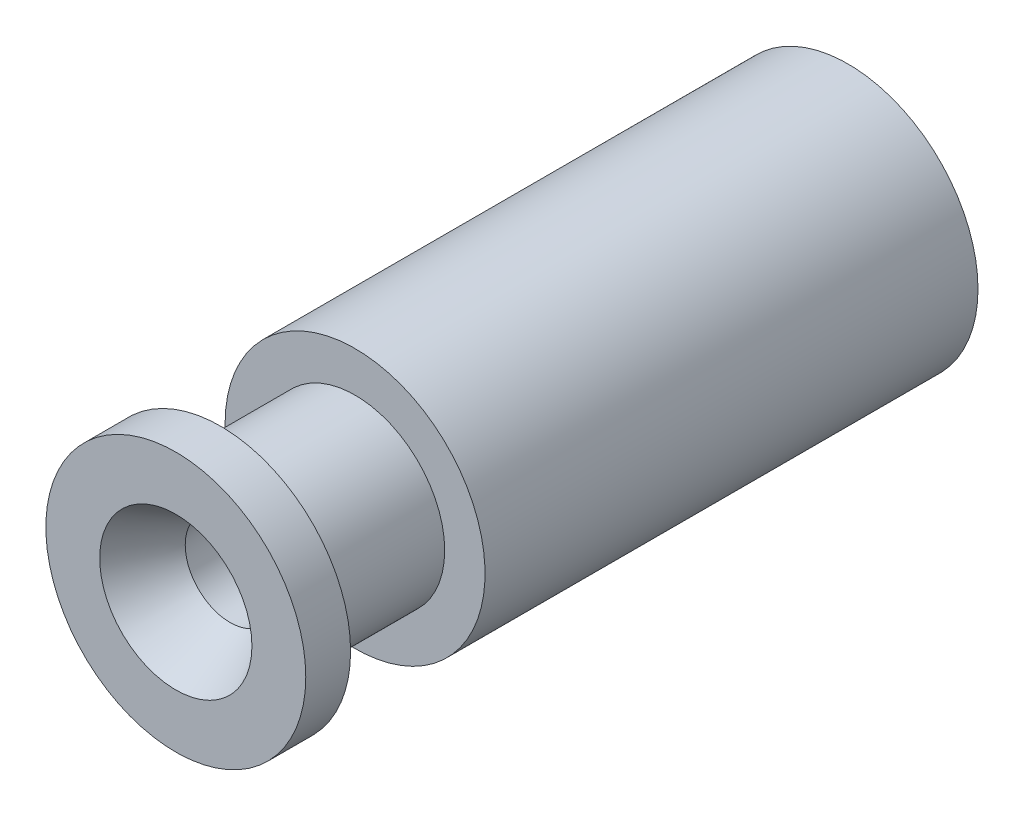
from build123d import *

# Parameters (mm, degrees)
SKETCH1_R                       = 2.9
BOSS_EXTRUDE1_DEPTH             = 15
SKETCH2_R                       = 1
CUT_EXTRUDE1_DEPTH              = 16
TAP_DRILL_FOR_M3X0_5_TAP1_D     = 2.5
TAP_DRILL_FOR_M3X0_5_TAP1_DEPTH = 11
TAP_DRILL_FOR_M3X0_5_TAP1_TIP   = 0.751075774
SKETCH5_W                       = 3
SKETCH5_H                       = 1.793791595
CHAMFER1_SIZE                   = 0.75
CHAMFER1_SIZE2                  = 1.299038106
CHAMFER2_SIZE                   = 1.21
CHAMFER2_SIZE2                  = 0.698593826


with BuildPart() as part:
    # Sketch1 → Boss-Extrude1 (new body)
    with BuildSketch(Plane.XY):
        Circle(SKETCH1_R)
    extrude(amount=BOSS_EXTRUDE1_DEPTH)

    # Sketch2 → Cut-Extrude1 (cut, through all)
    with BuildSketch(Plane(origin=(0, 0, 0), x_dir=(-1, 0, 0), z_dir=(0, 0, -1))):
        Circle(SKETCH2_R)
    extrude(amount=-CUT_EXTRUDE1_DEPTH, mode=Mode.SUBTRACT)

    # Tap Drill for M3x0.5 Tap1
    with Locations(Plane(origin=(0, 0, 0), x_dir=(-1, 0, 0), z_dir=(0, 0, -1))):
        with Locations((0, 0)):
            Hole(TAP_DRILL_FOR_M3X0_5_TAP1_D / 2, depth=TAP_DRILL_FOR_M3X0_5_TAP1_DEPTH)
            with Locations((0, 0, -(TAP_DRILL_FOR_M3X0_5_TAP1_DEPTH + TAP_DRILL_FOR_M3X0_5_TAP1_TIP / 2))):  # 118° drill point
                Cone(0, TAP_DRILL_FOR_M3X0_5_TAP1_D / 2, TAP_DRILL_FOR_M3X0_5_TAP1_TIP, mode=Mode.SUBTRACT)

    # Sketch5 → Cut-Revolve1 (revolve, cut)
    with BuildSketch(Plane(origin=(0, 0, 0), x_dir=(0, 0, -1), z_dir=(1, 0, 0))):
        with Locations((-12.5, 2.896895798)):
            Rectangle(SKETCH5_W, SKETCH5_H)
    revolve(axis=Axis((0, 0, 0), (0, 0, 1)), mode=Mode.SUBTRACT)

    # Chamfer1
    chamfer1_edges = [part.edges().sort_by_distance(p)[0] for p in [
        (-1.25, 0, 0),
    ]]
    chamfer1_side = [part.faces().sort_by_distance(p)[0] for p in [
        (-2.817975613, 0, 0),
    ]]
    chamfer(chamfer1_edges, length=CHAMFER1_SIZE, length2=CHAMFER1_SIZE2, reference=chamfer1_side[0])

    # Chamfer2
    chamfer2_edges = [part.edges().sort_by_distance(p)[0] for p in [
        (1, 0, 15),
    ]]
    chamfer2_side = [part.faces().sort_by_distance(p)[0] for p in [
        (1, 0, 13.075107577),
    ]]
    chamfer(chamfer2_edges, length=CHAMFER2_SIZE, length2=CHAMFER2_SIZE2, reference=chamfer2_side[0])


solid = part.part
